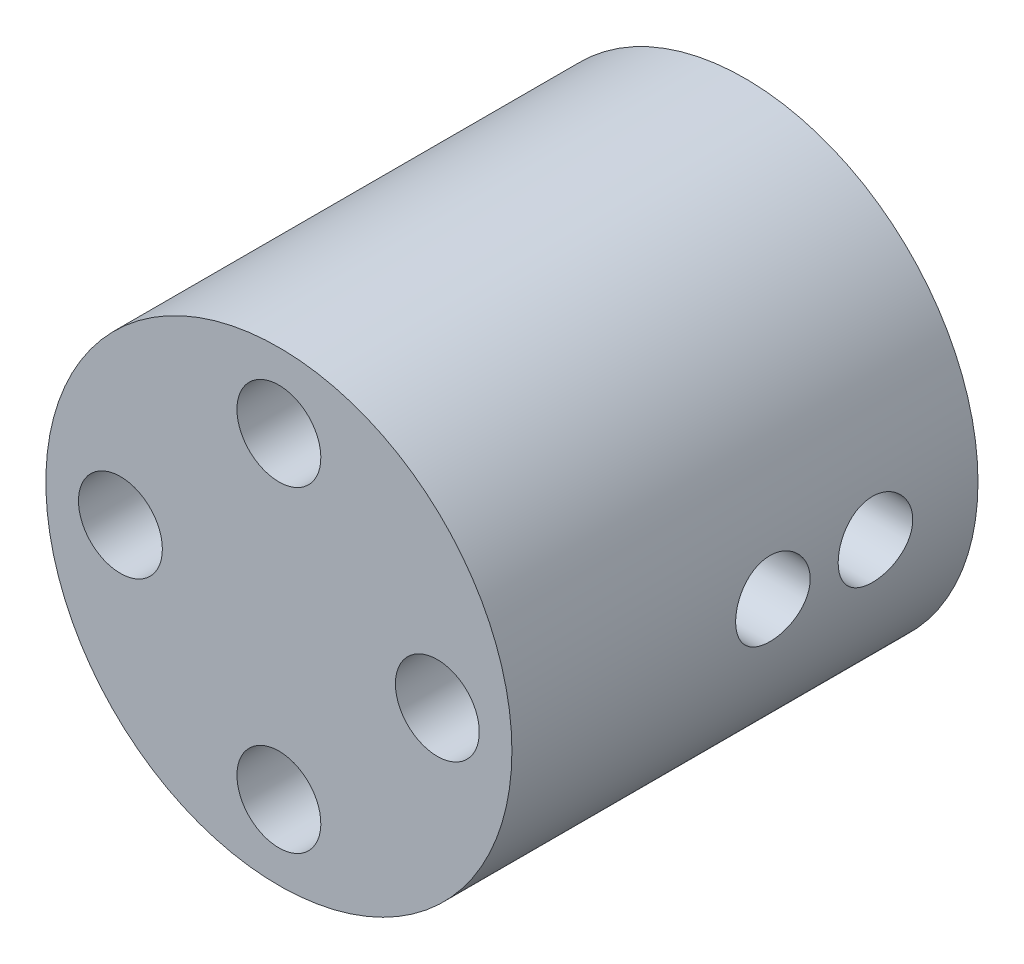
from build123d import *

# Parameters (mm, degrees)
SKETCH1_R           = 12.5
BOSS_EXTRUDE2_DEPTH = 25
SKETCH13_R          = 2.25
CUT_EXTRUDE7_DEPTH  = 10
SKETCH14_R          = 3.125
CUT_EXTRUDE8_DEPTH  = 3
CUT_EXTRUDE9_DEPTH  = 12
SKETCH16_R          = 1.5
CUT_EXTRUDE10_DEPTH = 10
CIRPATTERN1_COUNT   = 4
SKETCH18_R          = 2
CUT_EXTRUDE11_DEPTH = 5


with BuildPart() as part:
    # Sketch1 → Boss-Extrude2 (new body)
    with BuildSketch(Plane.XY):
        Circle(SKETCH1_R)
    extrude(amount=BOSS_EXTRUDE2_DEPTH)

    # Sketch13 → Cut-Extrude7 (cut)
    with BuildSketch(Plane.XY.offset(25)):
        with Locations((-8.5, 0)):
            Circle(SKETCH13_R)
    cut_extrude7 = extrude(amount=-CUT_EXTRUDE7_DEPTH, mode=Mode.SUBTRACT)

    # Sketch14 → Cut-Extrude8 (cut)
    with BuildSketch(Plane(origin=(0, 0, 0), x_dir=(-1, 0, 0), z_dir=(0, 0, -1))):
        Circle(SKETCH14_R)
    extrude(amount=-CUT_EXTRUDE8_DEPTH, mode=Mode.SUBTRACT)

    # Sketch15 → Cut-Extrude9 (cut)
    with BuildSketch(Plane(origin=(0, 0, 3), x_dir=(-1, 0, 0), z_dir=(0, 0, -1))):
        with BuildLine():
            Line((-2.548076923, -1.809123819), (-2.548076923, 1.809123819))
            ThreePointArc((-2.548076923, 1.809123819), (3.125, 0), (-2.548076923, -1.809123819))
        make_face()
    extrude(amount=-CUT_EXTRUDE9_DEPTH, mode=Mode.SUBTRACT)

    # Sketch16 → Cut-Extrude10 (cut)
    with BuildSketch(Plane.ZY.offset(-2.548076923)):
        with Locations((11, 0)):
            Circle(SKETCH16_R)
        with Locations((5.5, 0)):
            Circle(SKETCH16_R)
    extrude(amount=-CUT_EXTRUDE10_DEPTH, mode=Mode.SUBTRACT)

    # CirPattern1: Cut-Extrude7 ×4 about axis
    cirpattern1_axis = Axis((0, 0, 0), (0, 0, 1))
    for i in range(1, CIRPATTERN1_COUNT):
        add(cut_extrude7.rotate(cirpattern1_axis, i * 360 / CIRPATTERN1_COUNT), mode=Mode.SUBTRACT)

    # Sketch18 → Cut-Extrude11 (cut)
    with BuildSketch(Plane(origin=(12.5, 0, 0), x_dir=(0, 0, -1), z_dir=(1, 0, 0))):
        with Locations((-11, 0)):
            Circle(SKETCH18_R)
        with Locations((-5.5, 0)):
            Circle(SKETCH18_R)
    extrude(amount=-CUT_EXTRUDE11_DEPTH, mode=Mode.SUBTRACT)


solid = part.part
